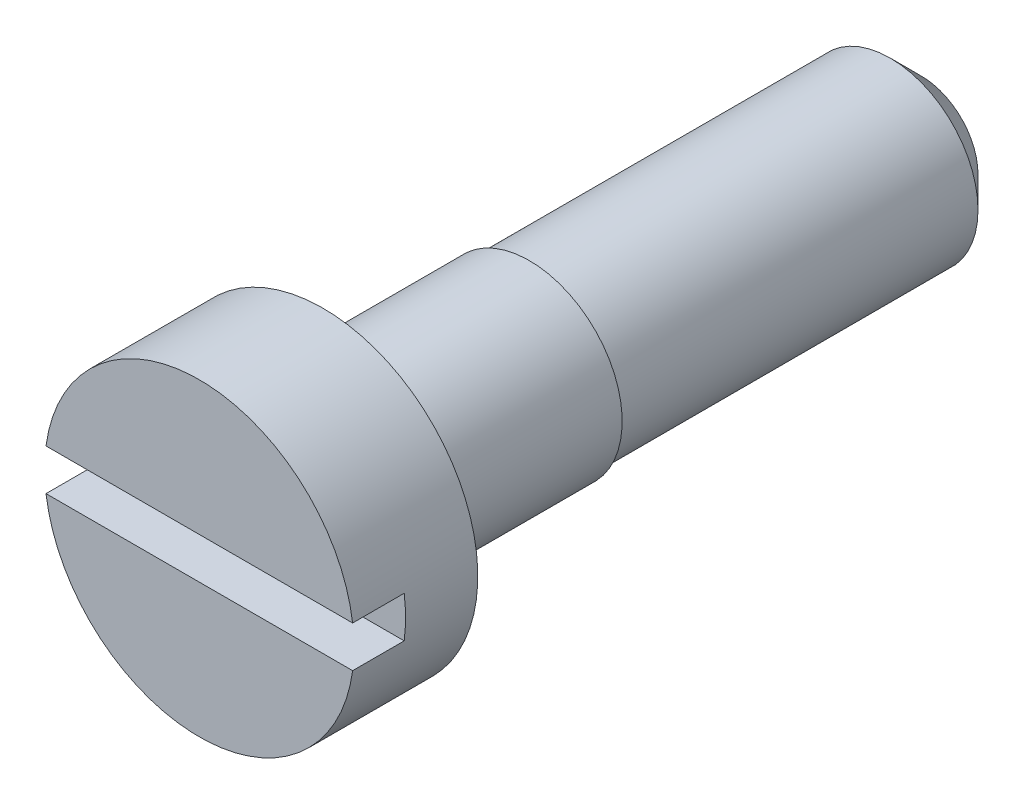
from build123d import *

# Parameters (mm, degrees)
SKETCH2_R           = 1.5
BOSS_EXTRUDE1_DEPTH = 7
SKETCH4_OUTSIDE_W   = 6.638
SKETCH4_OUTSIDE_H   = 6.638
SKETCH4_OUTSIDE_R   = 0.9
CUT_EXTRUDE1_DEPTH  = 5.8
SKETCH5_OUTSIDE_W   = 6.638
SKETCH5_OUTSIDE_H   = 6.638
SKETCH5_OUTSIDE_R   = 0.85
CUT_EXTRUDE2_DEPTH  = 3.8
SKETCH6_W           = 3.2
SKETCH6_H           = 0.4
CUT_EXTRUDE3_DEPTH  = 0.5
CHAMFER1_SIZE       = 0.3


with BuildPart() as part:
    # Sketch2 → Boss-Extrude1 (new body)
    with BuildSketch(Plane.XY):
        Circle(SKETCH2_R)
    extrude(amount=-BOSS_EXTRUDE1_DEPTH)

    # Sketch4 outside → Cut-Extrude1 (cut)
    with BuildSketch(Plane(origin=(0, 0, -7), x_dir=(-1, 0, 0), z_dir=(0, 0, -1))):
        Rectangle(SKETCH4_OUTSIDE_W, SKETCH4_OUTSIDE_H)
        Circle(SKETCH4_OUTSIDE_R, mode=Mode.SUBTRACT)
    extrude(amount=-CUT_EXTRUDE1_DEPTH, mode=Mode.SUBTRACT)

    # Sketch5 outside → Cut-Extrude2 (cut)
    with BuildSketch(Plane(origin=(0, 0, -7), x_dir=(-1, 0, 0), z_dir=(0, 0, -1))):
        Rectangle(SKETCH5_OUTSIDE_W, SKETCH5_OUTSIDE_H)
        Circle(SKETCH5_OUTSIDE_R, mode=Mode.SUBTRACT)
    extrude(amount=-CUT_EXTRUDE2_DEPTH, mode=Mode.SUBTRACT)

    # Sketch6 → Cut-Extrude3 (cut)
    with BuildSketch(Plane.XY):
        Rectangle(SKETCH6_W, SKETCH6_H)
    extrude(amount=-CUT_EXTRUDE3_DEPTH, mode=Mode.SUBTRACT)

    # Chamfer1
    chamfer1_edges = [part.edges().sort_by_distance(p)[0] for p in [
        (0.85, 0, -7),
    ]]
    chamfer(chamfer1_edges, length=CHAMFER1_SIZE)


solid = part.part
